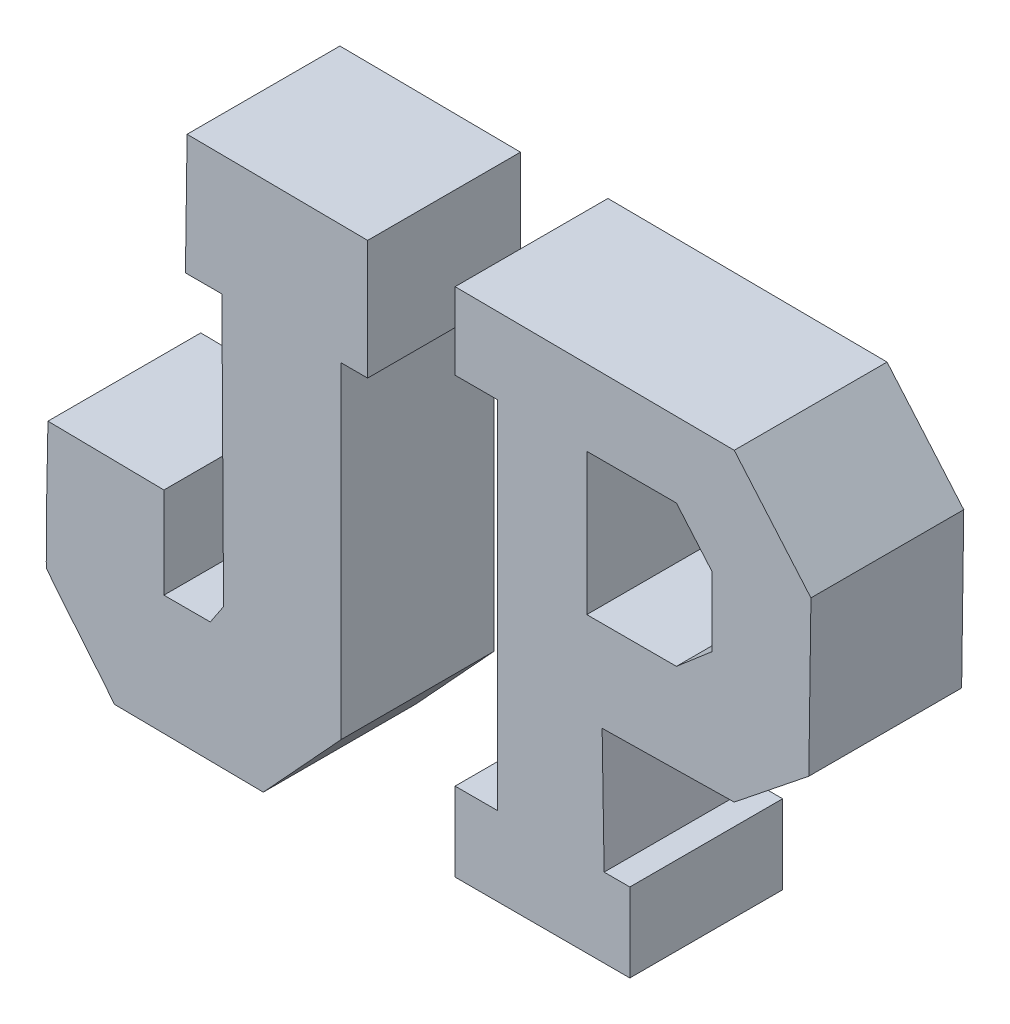
from build123d import *

# Parameters (mm, degrees)
BOSS_EXTRUDE1_DEPTH   = 18
BOSS_EXTRUDE1_2_DEPTH = 18


with BuildPart() as part:
    # Sketch2 → Boss-Extrude1 (new body)
    with BuildSketch(Plane.XY):
        with BuildLine():
            Line((41.451402768, 78.627112804), (62.71779308, 78.432008305))
            Line((62.71779308, 78.432008305), (62.71779308, 64.38448443))
            Line((62.71779308, 64.38448443), (59.596121107, 64.38448443))
            Line((59.596121107, 64.38448443), (59.596121107, 25.94889827))
            Line((59.596121107, 25.94889827), (50.426209689, 15.998568858))
            Line((50.426209689, 15.998568858), (32.866804844, 16.193673357))
            add(Edge.make_bspline(
                [(32.866804844, 16.193673357), (31.910610057, 17.627965538), (24.872485991, 25.751722249), (24.867520415, 26.144002768), (24.804131767, 31.151705999), (24.997590081, 36.159367013), (25.062624913, 41.167049135)],
                knots=[0, 0, 0, 0, 1, 1, 1, 2, 2, 2, 2], degree=3))
            Line((25.062624913, 41.167049135), (38.719939792, 40.971944637))
            Line((38.719939792, 40.971944637), (38.719939792, 30.241197232))
            Line((38.719939792, 30.241197232), (44.182865744, 30.241197232))
            Line((44.182865744, 30.241197232), (45.74370173, 32.582451211))
            Line((45.74370173, 32.582451211), (45.548597232, 64.38448443))
            Line((45.548597232, 64.38448443), (41.25629827, 64.38448443))
            Line((41.25629827, 64.38448443), (41.451402768, 78.627112804))
        make_face()
    extrude(amount=BOSS_EXTRUDE1_DEPTH)


with BuildPart() as body_2:
    # Sketch2 → Boss-Extrude1 2 (new body)
    with BuildSketch(Plane.XY):
        Polygon((73.021358937, 78.862525948), (105.897964848, 78.61155949), (114.932757312, 68.070968282), (114.681790855, 49.750416896), (105.897964848, 42.723356091), (90.338044493, 42.472389633), (90.572819566, 27.916335108), (93.600608438, 27.916335108), (93.600608438, 18.630576186), (73.021358937, 18.630576186), (73.021358937, 27.916335108), (78.040688083, 27.916335108), (78.040688083, 69.827733483), (73.021358937, 69.827733483), align=None)
        Polygon((88.530273253, 69.827733483), (88.530273253, 53.164474994), (99.086194651, 53.164474994), (103.268762855, 56.749533454), (103.268762855, 64.948070578), (99.086194651, 69.827733483), align=None, mode=Mode.SUBTRACT)
    extrude(amount=BOSS_EXTRUDE1_2_DEPTH)


solid = Compound([part.part, body_2.part])
